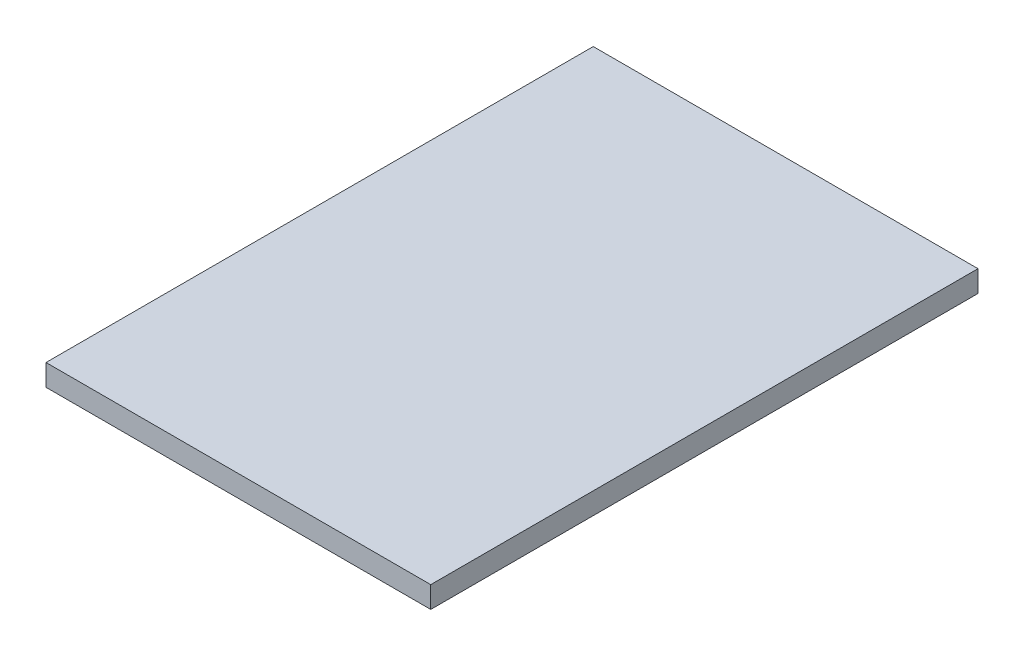
from build123d import *

# Parameters (mm, degrees)
SKETCH1_W           = 161
SKETCH1_H           = 229
BOSS_EXTRUDE1_DEPTH = 9


with BuildPart() as part:
    # Sketch1 → Boss-Extrude1 (new body)
    with BuildSketch(Plane(origin=(0, 0, 0), x_dir=(1, 0, 0), z_dir=(0, 1, 0))):
        Rectangle(SKETCH1_W, SKETCH1_H)
    extrude(amount=BOSS_EXTRUDE1_DEPTH)


solid = part.part
